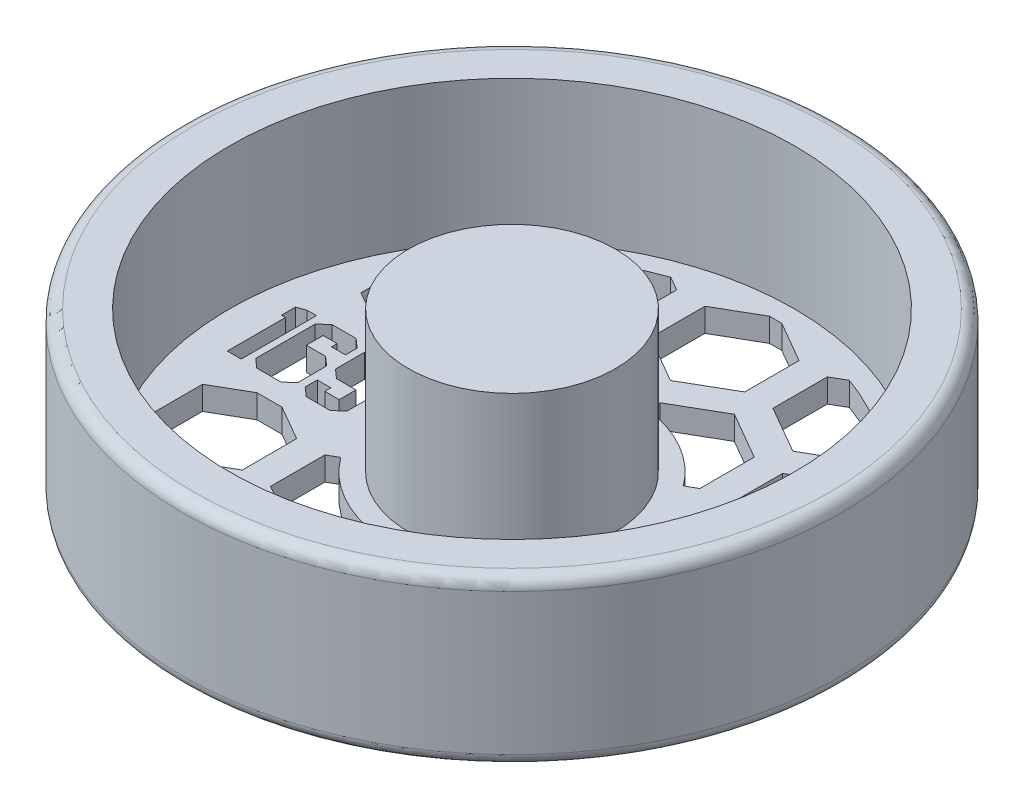
from build123d import *

# Parameters (mm, degrees)
CUT_EXTRUDE1_DEPTH      = 66.684910845
CUT_EXTRUDE1_DEPTH_BACK = 66.684910845
SKETCH2_W               = 1.935420596
SKETCH2_H               = 2.263100716
SKETCH2_W_2             = 1.881765372
CUT_EXTRUDE4_DEPTH      = 66.684910845
CUT_EXTRUDE4_DEPTH_BACK = 66.684910845


with BuildPart() as part:
    # Sketch1 → Revolve1 (revolve)
    with BuildSketch(Plane.XY, mode=Mode.PRIVATE) as revolve1_sk:
        with BuildLine():
            Line((0, 0), (0, 22.225))
            Line((0, 22.225), (13.97, 22.225))
            Line((13.97, 22.225), (13.97, 3.175))
            Line((13.97, 3.175), (38.1, 3.175))
            Line((38.1, 3.175), (38.1, 22.225))
            Line((38.1, 22.225), (42.8625, 22.225))
            ThreePointArc((42.8625, 22.225), (43.985032015, 21.760032015), (44.45, 20.6375))
            Line((44.45, 20.6375), (44.45, 1.5875))
            ThreePointArc((44.45, 1.5875), (43.985032015, 0.464967985), (42.8625, 0))
            Line((42.8625, 0), (0, 0))
        make_face()
    revolve(revolve1_sk.sketch.rotate(Axis((0, 0, 0), (0, 1, 0)), 90), axis=Axis((0, 0, 0), (0, 1, 0)))

    # Sketch2 → Cut-Extrude1 (cut, two sides: drawn at the far end of the back side and taken through both)
    # profile 1 of 6: a face of its own
    with BuildSketch(Plane(origin=(0, 3.175, 0), x_dir=(1, 0, 0), z_dir=(0, 1, 0)).offset(-CUT_EXTRUDE1_DEPTH_BACK)):
        Polygon((-18.235829876, -4.018393059), (-19.437323651, -5.08), (-22.671967182, -5.08), (-23.875377216, -4.018393059), (-23.875377216, -2.383824972), (-22.045350811, -2.383824972), (-22.045350811, -3.203983402), (-20.109930215, -3.203983402), (-20.109930215, -0.940882686), (-22.729454923, -0.940882686), (-23.927116183, 0.120724255), (-23.927116183, 4.012644285), (-22.729454923, 5.08), (-19.450737458, 5.08), (-18.235829876, 4.006895511), align=None)
        with Locations((-21.077640513, 2.072433044)):
            Rectangle(SKETCH2_W, SKETCH2_H, mode=Mode.SUBTRACT)
    # profile 2 of 6: a face of its own
    with BuildSketch(Plane(origin=(0, 3.175, 0), x_dir=(1, 0, 0), z_dir=(0, 1, 0)).offset(-CUT_EXTRUDE1_DEPTH_BACK)):
        Polygon((-24.883328932, -4.018393059), (-26.086738966, -5.08), (-29.346293851, -5.08), (-30.549703885, -4.018393059), (-30.549703885, 4.012644285), (-29.359707657, 5.08), (-26.105901547, 5.08), (-24.902491513, 4.012644285), (-24.902491513, 2.441312712), (-26.784256884, 2.441312712), (-26.784256884, 3.203983402), (-28.673687288, 3.203983402), (-28.673687288, 0.940882686), (-26.086738966, 0.940882686), (-24.883328932, -0.113059223), align=None)
        with Locations((-27.732804602, -2.072433044)):
            Rectangle(SKETCH2_W_2, SKETCH2_H, mode=Mode.SUBTRACT)
    # profile 3 of 6: a face of its own
    with BuildSketch(Plane(origin=(0, 3.175, 0), x_dir=(1, 0, 0), z_dir=(0, 1, 0)).offset(-CUT_EXTRUDE1_DEPTH_BACK)):
        Polygon((-31.448428895, -5.08), (-33.324445492, -5.08), (-33.324445492, 2.770909091), (-33.860997737, 2.770909091), (-33.860997737, 4.646925688), (-32.703577895, 5.08), (-31.448428895, 5.08), align=None)
    # profile 4 of 6: a face of its own
    with BuildSketch(Plane(origin=(0, 3.175, 0), x_dir=(1, 0, 0), z_dir=(0, 1, 0)).offset(-CUT_EXTRUDE1_DEPTH_BACK)):
        with BuildLine():
            Line((19.147692308, 2.051538462), (18.463846154, 2.051538462))
            add(Edge.make_bspline(
                [(18.463846154, 2.051538462), (18.482372661, 2.128244612), (18.518590468, 2.278198863), (18.594132042, 2.492445528), (18.676426421, 2.695188738), (18.775244986, 2.88263219), (18.883032616, 3.058542943), (19.006526084, 3.218931152), (19.14002788, 3.367875951), (19.287692484, 3.500057342), (19.442549742, 3.619751713), (19.606781685, 3.721805409), (19.7770841, 3.80959685), (19.95463692, 3.881922041), (20.139968757, 3.936406181), (20.331404108, 3.975936141), (20.529444643, 4.001607081), (20.663877969, 4.004112456), (20.732139423, 4.005384615)],
                knots=[0, 0, 0, 0, 1.162005537, 2.271625781, 3.343758855, 4.383309926, 5.390229558, 6.379919256, 7.361854164, 8.333198761, 9.295911338, 10.242430842, 11.177959212, 12.116337295, 13.062827104, 14.020064771, 14.994644689, 16, 16, 16, 16], degree=3))
            add(Edge.make_bspline(
                [(20.732139423, 4.005384615), (20.831597279, 4.002381834), (21.028343525, 3.996441771), (21.317387645, 3.942199484), (21.596120319, 3.856365338), (21.861490625, 3.737768252), (22.107983327, 3.591491873), (22.327300396, 3.417397218), (22.516469097, 3.21884331), (22.67517057, 2.999534127), (22.799430997, 2.765152704), (22.891059044, 2.523924933), (22.946841104, 2.276423041), (22.954070431, 2.109311479), (22.957692308, 2.025588942)],
                knots=[0, 0, 0, 0, 1.083050992, 2.142477498, 3.193116406, 4.255571735, 5.30263384, 6.308962982, 7.297363603, 8.282367274, 9.249857812, 10.179914175, 11.08814088, 12, 12, 12, 12], degree=3))
            add(Edge.make_bspline(
                [(22.957692308, 2.025588942), (22.955159004, 1.945019864), (22.950201721, 1.787358679), (22.908109482, 1.557187877), (22.83727339, 1.340253879), (22.739150078, 1.135643463), (22.612132189, 0.944653954), (22.458267632, 0.766855643), (22.276470408, 0.601459933), (22.13870312, 0.506711824), (22.067776442, 0.457932692)],
                knots=[0, 0, 0, 0, 1.024540389, 2.004866551, 2.965041327, 3.920577974, 4.882998113, 5.874504559, 6.905732034, 8, 8, 8, 8], degree=3))
            add(Edge.make_bspline(
                [(22.067776442, 0.457932692), (22.148835291, 0.418791645), (22.309436314, 0.341241908), (22.528349181, 0.189155945), (22.727074156, 0.013555554), (22.837898824, -0.123479593), (22.893581731, -0.192331731)],
                knots=[0, 0, 0, 0, 1.015518401, 2.012035669, 3.001164323, 4, 4, 4, 4], degree=3))
            add(Edge.make_bspline(
                [(22.893581731, -0.192331731), (22.930247739, -0.24253175), (23.002979324, -0.342109728), (23.092754972, -0.502209033), (23.174199958, -0.664082847), (23.23766415, -0.832069896), (23.286810683, -1.004223143), (23.32194113, -1.180838188), (23.343765117, -1.362059254), (23.346890518, -1.484659568), (23.348461538, -1.546286058)],
                knots=[0, 0, 0, 0, 1.025084078, 2.033381695, 3.024893161, 4.013698104, 4.991890475, 5.976764909, 6.982997093, 8, 8, 8, 8], degree=3))
            add(Edge.make_bspline(
                [(23.348461538, -1.546286058), (23.344554626, -1.652987222), (23.336759188, -1.865887414), (23.267081746, -2.180429522), (23.159066633, -2.487897615), (23.005671818, -2.781974837), (22.818725985, -3.057122981), (22.596314896, -3.303306259), (22.34096563, -3.514921506), (22.056183046, -3.691727774), (21.747644612, -3.833063365), (21.417642894, -3.931159855), (21.070932777, -3.995050288), (20.833172889, -4.001901471), (20.712295673, -4.005384615)],
                knots=[0, 0, 0, 0, 0.955779014, 1.907060117, 2.875433937, 3.871313158, 4.872415639, 5.851225146, 6.836215519, 7.83643374, 8.849228613, 9.86973379, 10.916971861, 12, 12, 12, 12], degree=3))
            add(Edge.make_bspline(
                [(20.712295673, -4.005384615), (20.630828511, -4.003494391), (20.470528301, -3.99977506), (20.234866742, -3.974349077), (20.009920642, -3.927910608), (19.795385861, -3.865419412), (19.59107181, -3.786189391), (19.397601958, -3.687524111), (19.213786019, -3.571457355), (19.041358588, -3.436619087), (18.88034022, -3.285783713), (18.735010004, -3.116273525), (18.602944969, -2.931222035), (18.487681281, -2.728479838), (18.38396883, -2.510667021), (18.29866629, -2.274994576), (18.223586281, -2.023569362), (18.188679138, -1.848357825), (18.170769231, -1.758461538)],
                knots=[0, 0, 0, 0, 1.048658725, 2.063410685, 3.046034179, 4.001477787, 4.936774919, 5.862367409, 6.792675028, 7.730719943, 8.675894397, 9.627829632, 10.600096036, 11.597688215, 12.626045268, 13.701542398, 14.82072376, 16, 16, 16, 16], degree=3))
            Line((18.170769231, -1.758461538), (18.854615385, -1.758461538))
            add(Edge.make_bspline(
                [(18.854615385, -1.758461538), (18.872431579, -1.81713339), (18.907085625, -1.931255238), (18.966073782, -2.095499561), (19.03327842, -2.246066522), (19.105373545, -2.384060634), (19.181091191, -2.510840893), (19.265814542, -2.623054905), (19.353268509, -2.725631431), (19.419190987, -2.783422843), (19.451454327, -2.811706731)],
                knots=[0, 0, 0, 0, 1.198163088, 2.33053128, 3.407730985, 4.417276592, 5.372219308, 6.28897303, 7.162600585, 8, 8, 8, 8], degree=3))
            add(Edge.make_bspline(
                [(19.451454327, -2.811706731), (19.494118874, -2.844599732), (19.579316271, -2.910284201), (19.71814882, -2.994107747), (19.864158658, -3.066739465), (20.020509463, -3.122221111), (20.183827334, -3.169198761), (20.356752055, -3.199941148), (20.537758008, -3.221033681), (20.661349539, -3.222894989), (20.724507212, -3.223846154)],
                knots=[0, 0, 0, 0, 0.946170439, 1.889420265, 2.845303464, 3.807233317, 4.801018734, 5.828864929, 6.890507805, 8, 8, 8, 8], degree=3))
            add(Edge.make_bspline(
                [(20.724507212, -3.223846154), (20.795816266, -3.22250524), (20.935254966, -3.219883199), (21.138719545, -3.195769803), (21.33228376, -3.160651589), (21.513798529, -3.106412466), (21.68564152, -3.039398155), (21.845403854, -2.955255055), (21.995182805, -2.856533119), (22.133059968, -2.744325007), (22.257038473, -2.621487352), (22.366199356, -2.493007466), (22.458999333, -2.35942706), (22.533857295, -2.220006923), (22.592967922, -2.075324396), (22.63320849, -1.924973459), (22.661188074, -1.770184553), (22.663466698, -1.664965484), (22.664615385, -1.611923077)],
                knots=[0, 0, 0, 0, 1.217147791, 2.380027433, 3.494444702, 4.572153297, 5.609568379, 6.639424714, 7.649109417, 8.668170816, 9.669597737, 10.625200337, 11.543417969, 12.441394052, 13.322311151, 14.205496177, 15.095365482, 16, 16, 16, 16], degree=3))
            add(Edge.make_bspline(
                [(22.664615385, -1.611923077), (22.6612837, -1.540923533), (22.654636908, -1.39927773), (22.6038908, -1.190886897), (22.520421616, -0.990103354), (22.403568891, -0.800352748), (22.261323676, -0.624492071), (22.095066365, -0.467582157), (21.903416336, -0.338107273), (21.727024507, -0.248651399), (21.570781509, -0.187610681), (21.437071444, -0.146952615), (21.287378496, -0.112524028), (21.123512902, -0.080493311), (20.944239956, -0.053232547), (20.749754831, -0.030499223), (20.540018116, -0.012309105), (20.394821921, -0.004185977), (20.32, 0)],
                knots=[0, 0, 0, 0, 1.07054697, 2.135767047, 3.216561865, 4.33974944, 5.486079747, 6.621378074, 7.775625952, 8.963672916, 9.598146892, 10.304877434, 11.070270905, 11.915000392, 12.823868403, 13.805723172, 14.86925407, 16, 16, 16, 16], degree=3))
            Line((20.32, 0), (20.32, 0.781538462))
            add(Edge.make_bspline(
                [(20.32, 0.781538462), (20.414272824, 0.783138234), (20.598930127, 0.786271796), (20.868665727, 0.824171521), (21.126599053, 0.876598489), (21.367013845, 0.956902822), (21.586140473, 1.050172268), (21.776247721, 1.15870765), (21.934672195, 1.279353475), (22.060644014, 1.413971899), (22.155413363, 1.558349231), (22.224704848, 1.708826069), (22.265635844, 1.86672131), (22.271099747, 1.974478273), (22.273846154, 2.028641827)],
                knots=[0, 0, 0, 0, 1.321986639, 2.589447074, 3.816329219, 5.01088745, 6.139805852, 7.153945165, 8.075214402, 8.924034688, 9.728124013, 10.488707548, 11.240355623, 12, 12, 12, 12], degree=3))
            add(Edge.make_bspline(
                [(22.273846154, 2.028641827), (22.272943922, 2.068435089), (22.271148974, 2.147601897), (22.248512615, 2.263262761), (22.214496846, 2.375387678), (22.167732407, 2.483499825), (22.105139117, 2.586849392), (22.030232369, 2.686317495), (21.941038963, 2.781336237), (21.838832018, 2.869903104), (21.729078317, 2.954309272), (21.608791664, 3.025966962), (21.481598896, 3.087242783), (21.347359196, 3.137773184), (21.205636928, 3.175784549), (21.057097965, 3.203076866), (20.901459065, 3.22014056), (20.795276037, 3.222597283), (20.741298077, 3.223846154)],
                knots=[0, 0, 0, 0, 0.884392785, 1.759457502, 2.611959086, 3.489218968, 4.37281399, 5.2945488, 6.255912374, 7.266815255, 8.301784654, 9.332968512, 10.37626691, 11.440494194, 12.520033166, 13.637162961, 14.798855837, 16, 16, 16, 16], degree=3))
            add(Edge.make_bspline(
                [(20.741298077, 3.223846154), (20.654535303, 3.22081696), (20.485067425, 3.21490024), (20.24075952, 3.163077679), (20.013641427, 3.080393966), (19.840038959, 2.981697507), (19.711843183, 2.884269419), (19.620235678, 2.799181481), (19.530275023, 2.704622019), (19.447879578, 2.594766928), (19.364551664, 2.477055802), (19.288690075, 2.345504815), (19.214972688, 2.203545534), (19.170553423, 2.103188752), (19.147692308, 2.051538462)],
                knots=[0, 0, 0, 0, 1.472543308, 2.876219568, 4.221790263, 5.565193594, 6.249813518, 6.953379497, 7.687249741, 8.463570142, 9.283606569, 10.136032583, 11.040678096, 12, 12, 12, 12], degree=3))
        make_face()
    # profile 5 of 6: a face of its own
    with BuildSketch(Plane(origin=(0, 3.175, 0), x_dir=(1, 0, 0), z_dir=(0, 1, 0)).offset(-CUT_EXTRUDE1_DEPTH_BACK)):
        Polygon((28.037692308, 4.005384615), (24.850480769, -4.884615385), (24.13, -4.884615385), (27.317211538, 4.005384615), align=None)
    # profile 6 of 6: a face of its own
    with BuildSketch(Plane(origin=(0, 3.175, 0), x_dir=(1, 0, 0), z_dir=(0, 1, 0)).offset(-CUT_EXTRUDE1_DEPTH_BACK)):
        Polygon((32.783401442, 4.005384615), (32.922307692, 4.005384615), (32.922307692, -1.27), (33.801538462, -1.27), (33.801538462, -2.051538462), (32.922307692, -2.051538462), (32.922307692, -3.81), (32.238461538, -3.81), (32.238461538, -2.051538462), (28.623846154, -2.051538462), align=None)
        Polygon((32.238461538, -1.27), (32.238461538, 2.039326923), (29.967115385, -1.27), align=None, mode=Mode.SUBTRACT)
    extrude(amount=CUT_EXTRUDE1_DEPTH + CUT_EXTRUDE1_DEPTH_BACK, mode=Mode.SUBTRACT)


with BuildPart() as cut_extrude1_kept_piece:
    # of the separate pieces the step leaves, the one the design keeps (cut_extrude1_pieces_kept)
    add(part.part.solids().sort_by_distance((0, 0, -42.8625))[0])

    # Sketch3 → Cut-Extrude4 (cut, two sides: drawn at the far end of the back side and taken through both)
    with BuildSketch(Plane(origin=(0, 3.175, 0), x_dir=(1, 0, 0), z_dir=(0, 1, 0)).offset(-CUT_EXTRUDE4_DEPTH_BACK)):
        with BuildLine():
            ThreePointArc((-1.905, -16.399727894), (-8.255, -14.298079416), (-13.250080971, -9.849642341))
            Line((-13.250080971, -9.849642341), (-14.605, -10.631905207))
            Line((-14.605, -10.631905207), (-14.605, -17.964253626))
            Line((-14.605, -17.964253626), (-8.255, -21.630427835))
            Line((-8.255, -21.630427835), (-1.905, -17.964253626))
            Line((-1.905, -17.964253626), (-1.905, -16.399727894))
        make_face()
        with BuildLine():
            Line((14.605, -10.631905207), (13.250080971, -9.849642341))
            ThreePointArc((13.250080971, -9.849642341), (8.255, -14.298079416), (1.905, -16.399727894))
            Line((1.905, -16.399727894), (1.905, -17.964253626))
            Line((1.905, -17.964253626), (8.255, -21.630427835))
            Line((8.255, -21.630427835), (14.605, -17.964253626))
            Line((14.605, -17.964253626), (14.605, -10.631905207))
        make_face()
        with BuildLine():
            Line((-18.415, -10.631905207), (-23.081846715, -7.9375))
            Line((-23.081846715, -7.9375), (-26.448153285, -7.9375))
            Line((-26.448153285, -7.9375), (-31.115, -10.631905207))
            Line((-31.115, -10.631905207), (-31.115, -17.215410974))
            ThreePointArc((-31.115, -17.215410974), (-30.795863359, -17.78), (-30.46648324, -18.338674952))
            Line((-30.46648324, -18.338674952), (-24.765, -21.630427835))
            Line((-24.765, -21.630427835), (-18.415, -17.964253626))
            Line((-18.415, -17.964253626), (-18.415, -10.631905207))
        make_face()
        with BuildLine():
            Line((26.448153285, -7.9375), (23.081846715, -7.9375))
            Line((23.081846715, -7.9375), (18.415, -10.631905207))
            Line((18.415, -10.631905207), (18.415, -17.964253626))
            Line((18.415, -17.964253626), (24.765, -21.630427835))
            Line((24.765, -21.630427835), (30.46648324, -18.338674952))
            ThreePointArc((30.46648324, -18.338674952), (30.795863359, -17.78), (31.115, -17.215410974))
            Line((31.115, -17.215410974), (31.115, -10.631905207))
            Line((31.115, -10.631905207), (26.448153285, -7.9375))
        make_face()
        with BuildLine():
            Line((-14.605, 10.737746374), (-13.194804504, 9.923569625))
            ThreePointArc((-13.194804504, 9.923569625), (-8.214997291, 14.321100499), (-1.905, 16.399727894))
            Line((-1.905, 16.399727894), (-1.905, 18.070094793))
            Line((-1.905, 18.070094793), (-8.255, 21.736269002))
            Line((-8.255, 21.736269002), (-14.605, 18.070094793))
            Line((-14.605, 18.070094793), (-14.605, 10.737746374))
        make_face()
        with BuildLine():
            ThreePointArc((1.905, 16.399727894), (8.214997291, 14.321100499), (13.194804504, 9.923569625))
            Line((13.194804504, 9.923569625), (14.605, 10.737746374))
            Line((14.605, 10.737746374), (14.605, 18.070094793))
            Line((14.605, 18.070094793), (8.255, 21.736269002))
            Line((8.255, 21.736269002), (1.905, 18.070094793))
            Line((1.905, 18.070094793), (1.905, 16.399727894))
        make_face()
        with BuildLine():
            Line((-26.264831006, 7.9375), (-23.265168994, 7.9375))
            Line((-23.265168994, 7.9375), (-18.415, 10.737746374))
            Line((-18.415, 10.737746374), (-18.415, 18.070094793))
            Line((-18.415, 18.070094793), (-24.765, 21.736269002))
            Line((-24.765, 21.736269002), (-30.367930984, 18.50141529))
            ThreePointArc((-30.367930984, 18.50141529), (-30.748189416, 17.862319212), (-31.115, 17.215410974))
            Line((-31.115, 17.215410974), (-31.115, 10.737746374))
            Line((-31.115, 10.737746374), (-26.264831006, 7.9375))
        make_face()
        with BuildLine():
            Line((18.415, 10.737746374), (23.265168994, 7.9375))
            Line((23.265168994, 7.9375), (26.264831006, 7.9375))
            Line((26.264831006, 7.9375), (31.115, 10.737746374))
            Line((31.115, 10.737746374), (31.115, 17.215410974))
            ThreePointArc((31.115, 17.215410974), (30.748189416, 17.862319212), (30.367930984, 18.50141529))
            Line((30.367930984, 18.50141529), (24.765, 21.736269002))
            Line((24.765, 21.736269002), (18.415, 18.070094793))
            Line((18.415, 18.070094793), (18.415, 10.737746374))
        make_face()
        with BuildLine():
            Line((-22.86, -25.035825791), (-22.86, -27.238465449))
            ThreePointArc((-22.86, -27.238465449), (-17.728085176, -30.825778108), (-12.046523441, -33.457359026))
            Line((-12.046523441, -33.457359026), (-10.16, -32.368174209))
            Line((-10.16, -32.368174209), (-10.16, -25.035825791))
            Line((-10.16, -25.035825791), (-16.51, -21.369651581))
            Line((-16.51, -21.369651581), (-22.86, -25.035825791))
        make_face()
        with BuildLine():
            ThreePointArc((12.046523441, -33.457359026), (17.728085176, -30.825778108), (22.86, -27.238465449))
            Line((22.86, -27.238465449), (22.86, -25.035825791))
            Line((22.86, -25.035825791), (16.51, -21.369651581))
            Line((16.51, -21.369651581), (10.16, -25.035825791))
            Line((10.16, -25.035825791), (10.16, -32.368174209))
            Line((10.16, -32.368174209), (12.046523441, -33.457359026))
        make_face()
        with BuildLine():
            Line((-6.35, -32.368174209), (-0.838730155, -35.550107338))
            ThreePointArc((-0.838730155, -35.550107338), (0, -35.56), (0.838730155, -35.550107338))
            Line((0.838730155, -35.550107338), (6.35, -32.368174209))
            Line((6.35, -32.368174209), (6.35, -25.035825791))
            Line((6.35, -25.035825791), (0, -21.369651581))
            Line((0, -21.369651581), (-6.35, -25.035825791))
            Line((-6.35, -25.035825791), (-6.35, -32.368174209))
        make_face()
        with BuildLine():
            ThreePointArc((-12.046523441, 33.457359026), (-17.728085176, 30.825778108), (-22.86, 27.238465449))
            Line((-22.86, 27.238465449), (-22.86, 25.035825791))
            Line((-22.86, 25.035825791), (-16.51, 21.369651581))
            Line((-16.51, 21.369651581), (-10.16, 25.035825791))
            Line((-10.16, 25.035825791), (-10.16, 32.368174209))
            Line((-10.16, 32.368174209), (-12.046523441, 33.457359026))
        make_face()
        with BuildLine():
            Line((22.86, 25.035825791), (22.86, 27.238465449))
            ThreePointArc((22.86, 27.238465449), (17.728085176, 30.825778108), (12.046523441, 33.457359026))
            Line((12.046523441, 33.457359026), (10.16, 32.368174209))
            Line((10.16, 32.368174209), (10.16, 25.035825791))
            Line((10.16, 25.035825791), (16.51, 21.369651581))
            Line((16.51, 21.369651581), (22.86, 25.035825791))
        make_face()
        with BuildLine():
            ThreePointArc((0.838730155, 35.550107338), (0, 35.56), (-0.838730155, 35.550107338))
            Line((-0.838730155, 35.550107338), (-6.35, 32.368174209))
            Line((-6.35, 32.368174209), (-6.35, 25.035825791))
            Line((-6.35, 25.035825791), (0, 21.369651581))
            Line((0, 21.369651581), (6.35, 25.035825791))
            Line((6.35, 25.035825791), (6.35, 32.368174209))
            Line((6.35, 32.368174209), (0.838730155, 35.550107338))
        make_face()
    extrude(amount=CUT_EXTRUDE4_DEPTH + CUT_EXTRUDE4_DEPTH_BACK, mode=Mode.SUBTRACT)


solid = cut_extrude1_kept_piece.part
